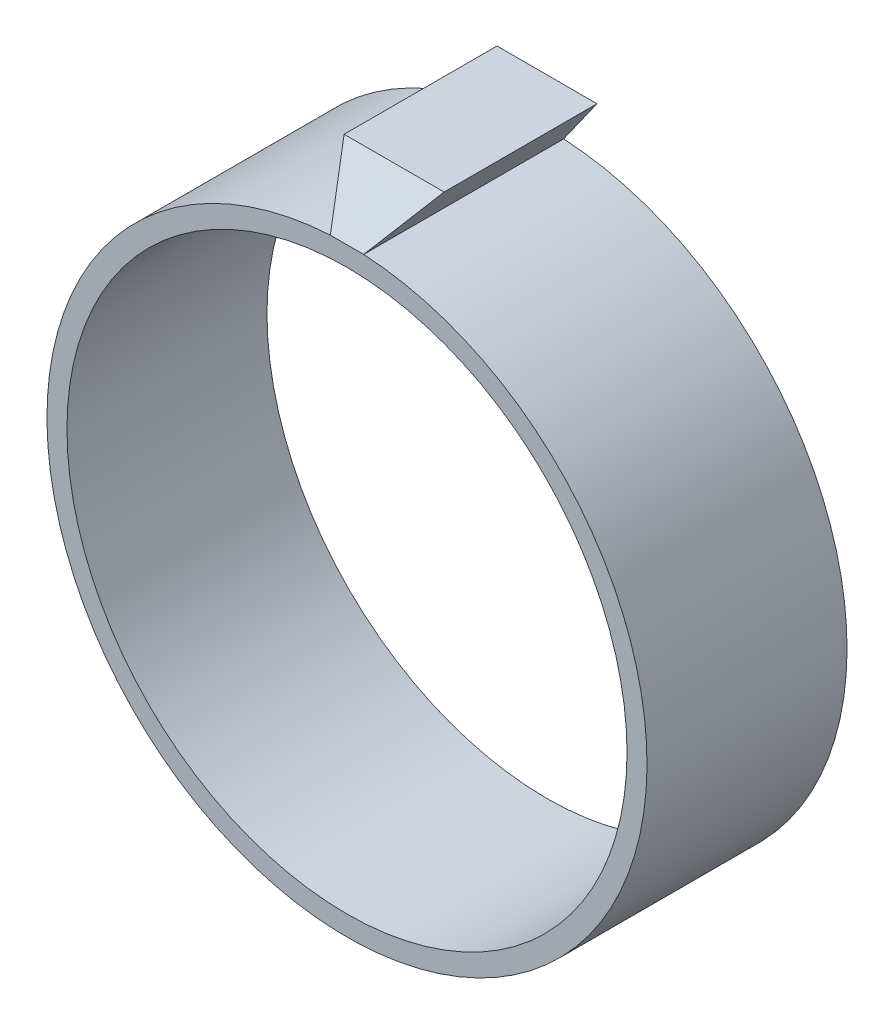
from build123d import *

# Parameters (mm, degrees)
SKETCH1_R                      = 42
BOSS_EXTRUDE1_DEPTH            = 30
CUT_EXTRUDE1_REACH             = 47
CUT_EXTRUDE1_DIRECTION_2_REACH = 47


with BuildPart() as part:
    # Sketch1 → Boss-Extrude1 (new body)
    with BuildSketch(Plane.XY):
        with BuildLine():
            ThreePointArc((2.5, 44.930501889), (15.285447634, 42.324403016), (26.785714286, 36.159722209))
            ThreePointArc((26.785714286, 36.159722209), (-12.910485027, -43.108228639), (-2.5, 44.930501889))
            Line((-2.5, 44.930501889), (-7.5, 52))
            Line((-7.5, 52), (7.5, 52))
            Line((7.5, 52), (2.5, 44.930501889))
        make_face()
        Circle(SKETCH1_R, mode=Mode.SUBTRACT)
    extrude(amount=BOSS_EXTRUDE1_DEPTH)

    # Cut-Extrude1: up to this face of the body (flat: up to its plane)
    cut_extrude1_end = Plane(part.part.faces().sort_by_distance((-5, 48.465250945, 15))[0])
    # Sketch3 → Cut-Extrude1 (cut, up to the picked face)
    with BuildSketch(Plane(origin=(0, 0, 0), x_dir=(0, 0, -1), z_dir=(1, 0, 0)), mode=Mode.PRIVATE) as cut_extrude1_sk1:
        Polygon((-30, 44.930501889), (-22.930501889, 52), (-30, 52), align=None)
    cut_extrude1_tool1 = split(extrude(cut_extrude1_sk1.sketch, amount=-CUT_EXTRUDE1_REACH, mode=Mode.PRIVATE), bisect_by=cut_extrude1_end, keep=Keep.BOTH, mode=Mode.PRIVATE)
    add(cut_extrude1_tool1.solids().sort_by_distance((0, 49.643501, 27.643501))[0], mode=Mode.SUBTRACT)

    # Cut-Extrude1 direction 2: up to this face of the body (flat: up to its plane)
    cut_extrude1_direction_2_end = Plane(part.part.faces().sort_by_distance((5, 48.465250945, 15))[0])
    # Sketch3 → Cut-Extrude1 direction 2 (cut, up to the picked face)
    with BuildSketch(Plane(origin=(0, 0, 0), x_dir=(0, 0, -1), z_dir=(1, 0, 0)), mode=Mode.PRIVATE) as cut_extrude1_direction_2_sk1:
        Polygon((-30, 44.930501889), (-22.930501889, 52), (-30, 52), align=None)
    cut_extrude1_direction_2_tool1 = split(extrude(cut_extrude1_direction_2_sk1.sketch, amount=CUT_EXTRUDE1_DIRECTION_2_REACH, mode=Mode.PRIVATE), bisect_by=cut_extrude1_direction_2_end, keep=Keep.BOTH, mode=Mode.PRIVATE)
    add(cut_extrude1_direction_2_tool1.solids().sort_by_distance((0, 49.643501, 27.643501))[0], mode=Mode.SUBTRACT)


solid = part.part
